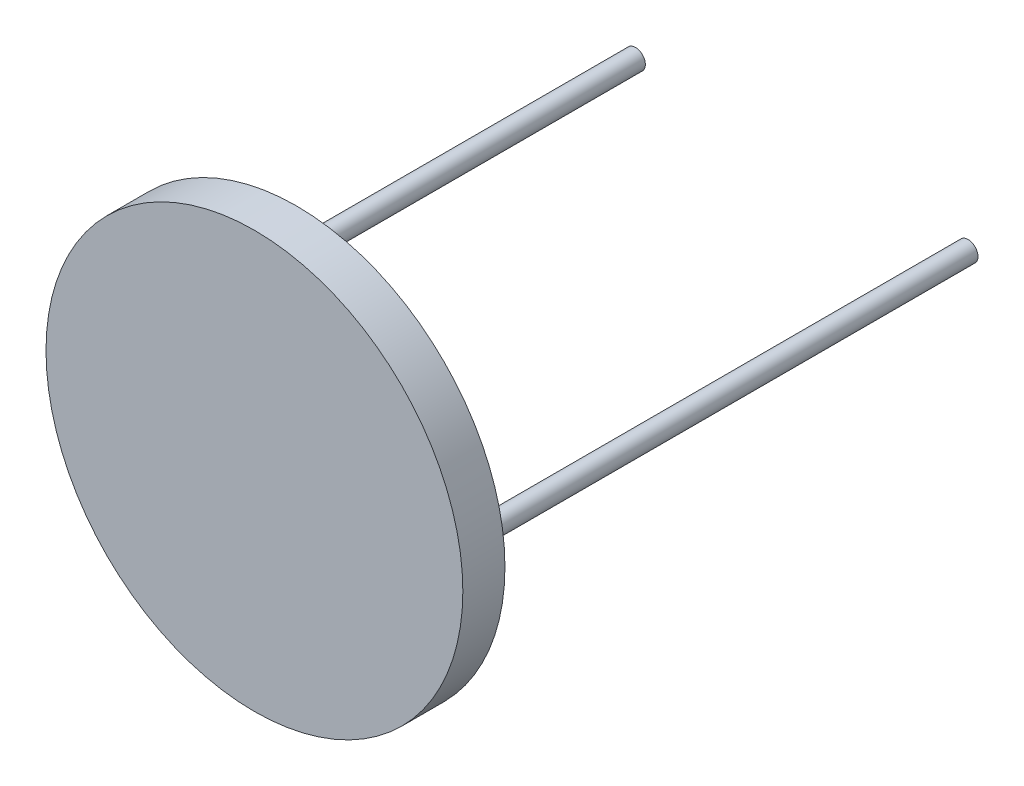
from build123d import *

# Parameters (mm, degrees)
SKETCH1_R           = 9.9
BOSS_EXTRUDE1_DEPTH = 2
SKETCH2_R           = 0.47
BOSS_EXTRUDE2_DEPTH = 24


with BuildPart() as part:
    # Sketch1 → Boss-Extrude1 (new body)
    with BuildSketch(Plane.XY):
        Circle(SKETCH1_R)
    extrude(amount=BOSS_EXTRUDE1_DEPTH)

    # Sketch2 → Boss-Extrude2 (add)
    with BuildSketch(Plane(origin=(0, 0, 0), x_dir=(-1, 0, 0), z_dir=(0, 0, -1))):
        with Locations((-7.9, 0)):
            Circle(SKETCH2_R)
        with Locations((7.9, 0)):
            Circle(SKETCH2_R)
    extrude(amount=BOSS_EXTRUDE2_DEPTH)


solid = part.part
